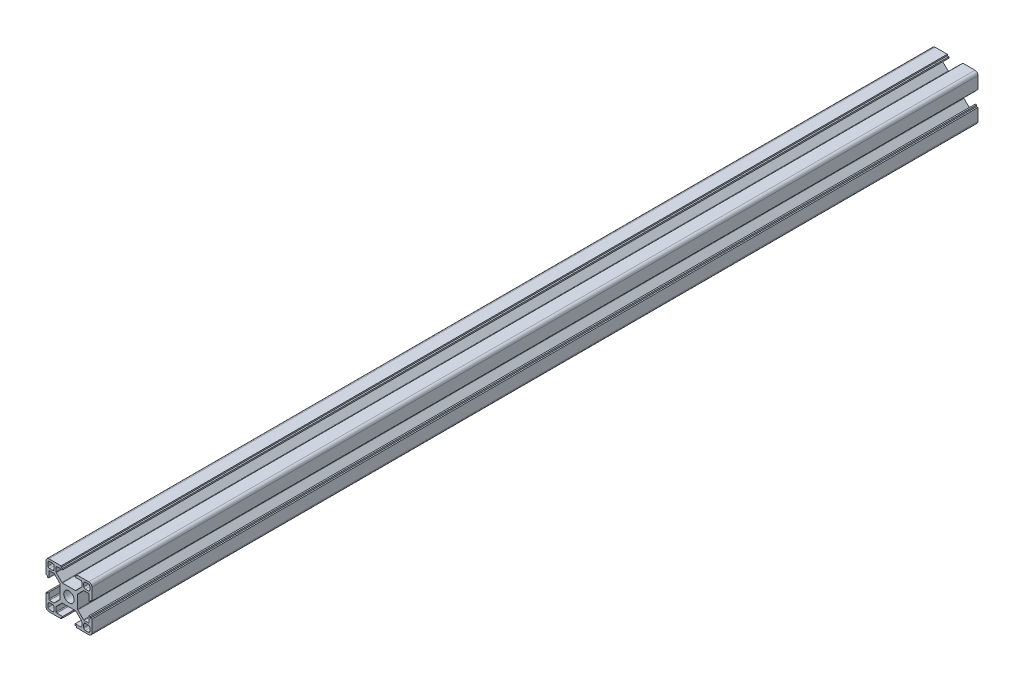
from build123d import *

# Parameters (mm, degrees)
SKETCH_1_W                       = 4
SKETCH_1_H                       = 4
EXTRUDE_1_DEPTH                  = 580
FILLET_1_R                       = 1
FILLET_2_R                       = 2
FILLET_3_R                       = 0.5
PATTERN_CIRCULAR_1_COUNT         = 4
FILLET_1_OF_PATTERN_CIRCULAR_1_R = 1
FILLET_2_OF_PATTERN_CIRCULAR_1_R = 2
FILLET_3_OF_PATTERN_CIRCULAR_1_R = 0.5
SKETCH_2_R                       = 3.4
CUT_EXTRUDE_1_DEPTH              = 581
SKETCH_3_R                       = 2.6
CUT_EXTRUDE_2_DEPTH              = 10


with BuildPart() as part:
    # 草图1 → 凸台-拉伸1 (new body)
    with BuildSketch(Plane.XY):
        Polygon((5.7, 0), (5.7, 4.427207794), (9.672792206, 8.4), (13.2, 8.4), (13.2, 4.1), (14.1, 4.1), (14.1, 5.1), (15, 5.1), (15, 15), (5.1, 15), (5.1, 14.1), (4.1, 14.1), (4.1, 13.2), (8.4, 13.2), (8.4, 9.672792206), (4.427207794, 5.7), (0, 5.7), (0, 0), align=None)
        with Locations((11.7, 11.7)):
            Rectangle(SKETCH_1_W, SKETCH_1_H, mode=Mode.SUBTRACT)
    extrude_1 = extrude(amount=EXTRUDE_1_DEPTH)

    # 圆角1
    fillet_1_edges = [part.edges().sort_by_distance(p)[0] for p in [
        (13.7, 9.7, 290),
        (13.7, 13.7, 290),
        (9.7, 13.7, 290),
        (9.7, 9.7, 290),
    ]]
    fillet(fillet_1_edges, radius=FILLET_1_R)

    # 圆角2
    fillet_2_edges = [part.edges().sort_by_distance(p)[0] for p in [
        (15, 15, 290),
    ]]
    fillet(fillet_2_edges, radius=FILLET_2_R)

    # 圆角3
    fillet_3_edges = [part.edges().sort_by_distance(p)[0] for p in [
        (4.427207794, 5.7, 290),
        (8.4, 9.672792206, 290),
        (8.4, 13.2, 290),
        (13.2, 8.4, 290),
        (9.672792206, 8.4, 290),
        (5.7, 4.427207794, 290),
    ]]
    fillet(fillet_3_edges, radius=FILLET_3_R)

    # 阵列(圆周)1: 凸台-拉伸1 ×4 about axis
    pattern_circular_1_axis = Axis((0, 0, 0), (0, 0, 1))
    for i in range(1, PATTERN_CIRCULAR_1_COUNT):
        add(extrude_1.rotate(pattern_circular_1_axis, i * 360 / PATTERN_CIRCULAR_1_COUNT))

    # 圆角1 of 阵列(圆周)1
    fillet_1_of_pattern_circular_1_edges = [part.edges().sort_by_distance(p)[0] for p in [
        (-9.7, 13.7, 290),
        (-13.7, 13.7, 290),
        (-13.7, 9.7, 290),
        (-9.7, 9.7, 290),
        (-13.7, -9.7, 290),
        (-13.7, -13.7, 290),
        (-9.7, -13.7, 290),
        (-9.7, -9.7, 290),
        (9.7, -13.7, 290),
        (13.7, -13.7, 290),
        (13.7, -9.7, 290),
        (9.7, -9.7, 290),
    ]]
    fillet(fillet_1_of_pattern_circular_1_edges, radius=FILLET_1_OF_PATTERN_CIRCULAR_1_R)

    # 圆角2 of 阵列(圆周)1
    fillet_2_of_pattern_circular_1_edges = [part.edges().sort_by_distance(p)[0] for p in [
        (-15, 15, 290),
        (-15, -15, 290),
        (15, -15, 290),
    ]]
    fillet(fillet_2_of_pattern_circular_1_edges, radius=FILLET_2_OF_PATTERN_CIRCULAR_1_R)

    # 圆角3 of 阵列(圆周)1
    fillet_3_of_pattern_circular_1_edges = [part.edges().sort_by_distance(p)[0] for p in [
        (-5.7, 4.427207794, 290),
        (-9.672792206, 8.4, 290),
        (-13.2, 8.4, 290),
        (-8.4, 13.2, 290),
        (-8.4, 9.672792206, 290),
        (-4.427207794, 5.7, 290),
        (-4.427207794, -5.7, 290),
        (-8.4, -9.672792206, 290),
        (-8.4, -13.2, 290),
        (-13.2, -8.4, 290),
        (-9.672792206, -8.4, 290),
        (-5.7, -4.427207794, 290),
        (5.7, -4.427207794, 290),
        (9.672792206, -8.4, 290),
        (13.2, -8.4, 290),
        (8.4, -13.2, 290),
        (8.4, -9.672792206, 290),
        (4.427207794, -5.7, 290),
    ]]
    fillet(fillet_3_of_pattern_circular_1_edges, radius=FILLET_3_OF_PATTERN_CIRCULAR_1_R)

    # 草图2 → 切除-拉伸1 (cut, through all)
    with BuildSketch(Plane.XY.offset(580)):
        Circle(SKETCH_2_R)
    extrude(amount=-CUT_EXTRUDE_1_DEPTH, mode=Mode.SUBTRACT)

    # 草图3 → 切除-拉伸2 (cut, symmetric)
    with BuildSketch(Plane(origin=(0, 0, 0), x_dir=(1, 0, 0), z_dir=(0, 1, 0))):
        with Locations((0, -30)):
            Circle(SKETCH_3_R)
        with Locations((0, -90)):
            Circle(SKETCH_3_R)
    extrude(amount=CUT_EXTRUDE_2_DEPTH, both=True, mode=Mode.SUBTRACT)


solid = part.part
